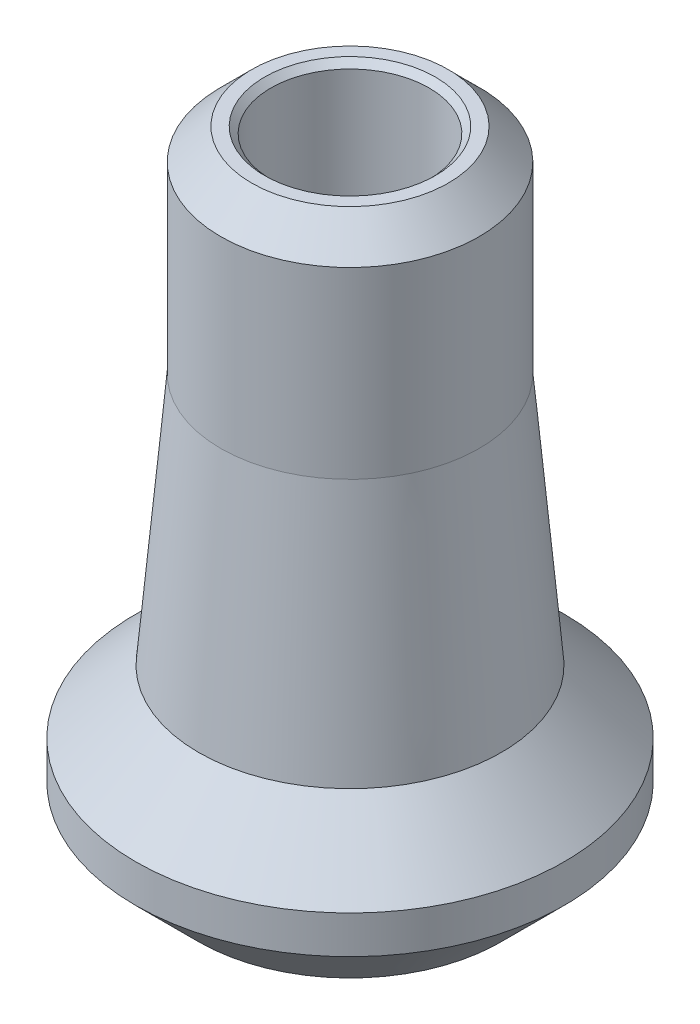
from build123d import *

# Parameters (mm, degrees)
CHAMFER1_SIZE = 0.254


with BuildPart() as part:
    # Sketch1 → Revolve1 (revolve)
    with BuildSketch(Plane.XY, mode=Mode.PRIVATE) as revolve1_sk:
        Polygon((-3.9624, 0), (-3.1877, 0), (-3.1877, -25.4), (-6.096, -25.4), (-8.636, -22.86), (-8.636, -21.336), (-6.096, -18.796), (-5.207, -8.634683503), (-5.207, -1.2446), align=None)
    revolve(revolve1_sk.sketch.rotate(Axis((0, 0, 0), (0, -1, 0)), 270), axis=Axis((0, 0, 0), (0, -1, 0)))

    # Chamfer1
    chamfer1_edges = [part.edges().sort_by_distance(p)[0] for p in [
        (0, 0, -3.1877),
        (0, -25.4, -3.1877),
    ]]
    chamfer(chamfer1_edges, length=CHAMFER1_SIZE)


solid = part.part
